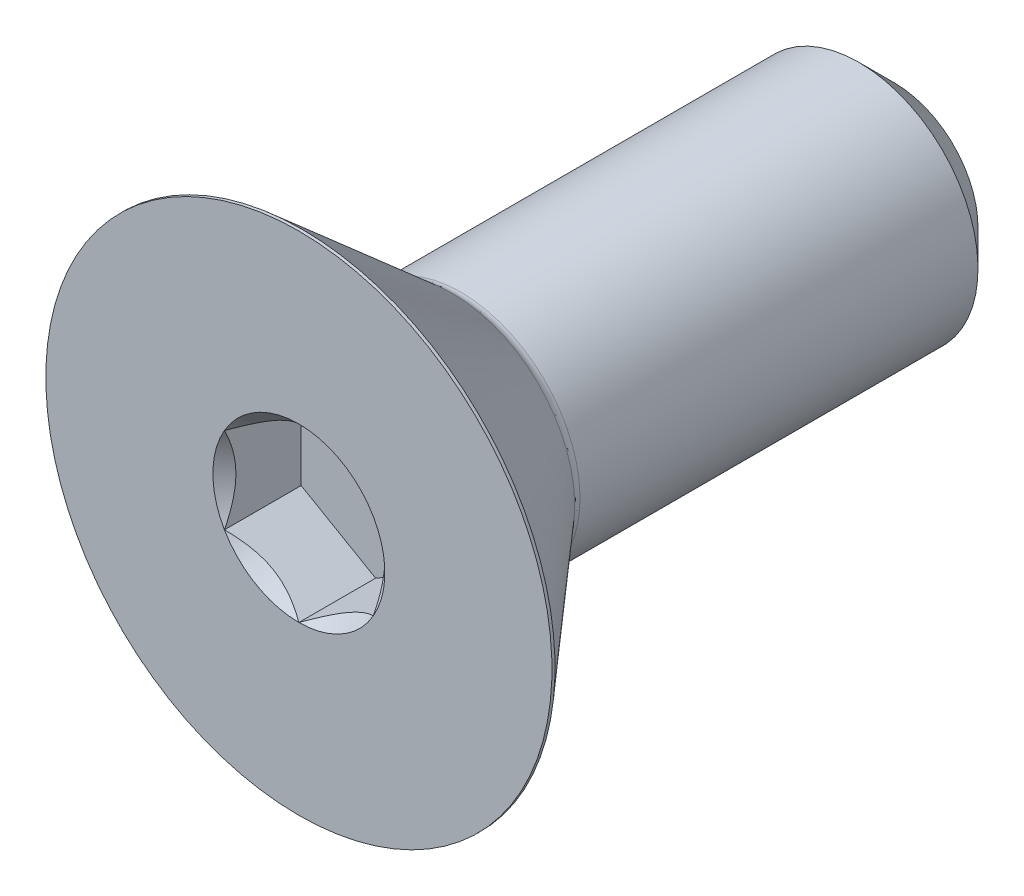
from build123d import *

# Parameters (mm, degrees)
SKETCH10_R         = 2.291358881
CUT_EXTRUDE2_DEPTH = 2.0447
CUT_EXTRUDE2_TAPER = 45
CUT_EXTRUDE1_DEPTH = 2.0447


with BuildPart() as part:
    # Sketch11 → Revolve1 (revolve)
    with BuildSketch(Plane(origin=(0, 0, 0), x_dir=(0, 0, -1), z_dir=(1, 0, 0))):
        with BuildLine():
            Line((-7.855712, 6.7437), (-3.8481, 3.259936038))
            ThreePointArc((-3.8481, 3.259936038), (-3.742193592, 3.196928347), (-3.620928247, 3.175))
            Line((-3.620928247, 3.175), (6.985, 3.175))
            Line((6.985, 3.175), (7.9375, 2.2225))
            Line((7.9375, 2.2225), (7.9375, 0))
            Line((7.9375, 0), (-7.9375, 0))
            Line((-7.9375, 0), (-7.9375, 6.7437))
            Line((-7.9375, 6.7437), (-7.855712, 6.7437))
        make_face()
    revolve(axis=Axis((0, 0, -7.9375), (0, 0, 1)))

    # Sketch10 → Cut-Extrude2 (cut)
    with BuildSketch(Plane.XY.offset(7.9375)):
        Circle(SKETCH10_R)
    extrude(amount=-CUT_EXTRUDE2_DEPTH, taper=CUT_EXTRUDE2_TAPER, mode=Mode.SUBTRACT)

    # Sketch9 → Cut-Extrude1 (cut)
    with BuildSketch(Plane.XY.offset(7.9375)):
        Polygon((1.984375, -1.14567944), (1.984375, 1.14567944), (0, 2.291358881), (-1.984375, 1.14567944), (-1.984375, -1.14567944), (0, -2.291358881), align=None)
    extrude(amount=-CUT_EXTRUDE1_DEPTH, mode=Mode.SUBTRACT)


solid = part.part
